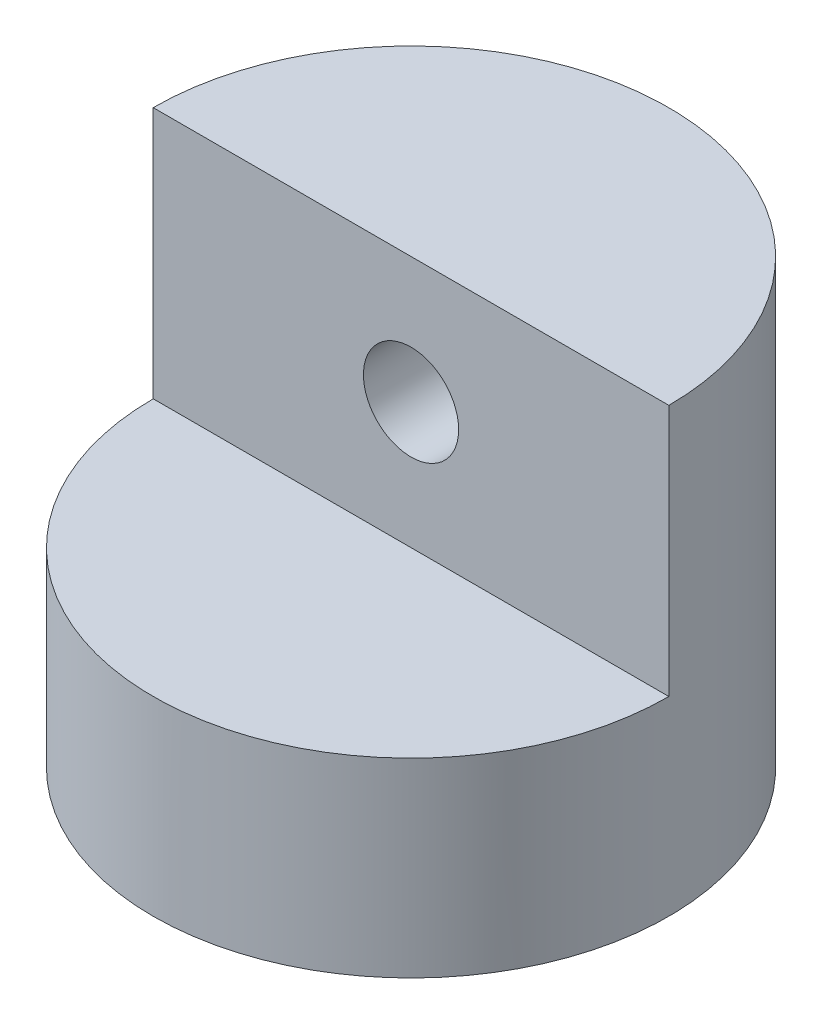
from build123d import *

# Parameters (mm, degrees)
SKETCH1_R           = 32.5
BOSS_EXTRUDE1_DEPTH = 55.788
CUT_EXTRUDE1_DEPTH  = 31.788
SKETCH3_R           = 8
SKETCH3_R_2         = 6
BOSS_EXTRUDE2_DEPTH = 2
SKETCH5_R           = 6
CUT_EXTRUDE3_DEPTH  = 46


with BuildPart() as part:
    # Sketch1 → Boss-Extrude1 (new body)
    with BuildSketch(Plane(origin=(0, 0, 0), x_dir=(1, 0, 0), z_dir=(0, 1, 0))):
        with Locations(Location((0, 0, 0), (0, 0, 270))):
            Circle(SKETCH1_R)
    extrude(amount=BOSS_EXTRUDE1_DEPTH)

    # Sketch2 → Cut-Extrude1 (cut)
    with BuildSketch(Plane(origin=(0, 55.788, 0), x_dir=(1, 0, 0), z_dir=(0, 1, 0))):
        with BuildLine():
            Line((32.5, 0), (-32.5, 0))
            ThreePointArc((-32.5, 0), (0, -32.5), (32.5, 0))
        make_face()
    extrude(amount=-CUT_EXTRUDE1_DEPTH, mode=Mode.SUBTRACT)

    # Sketch3 → Boss-Extrude2 (add)
    with BuildSketch(Plane(origin=(0, 0, 0), x_dir=(-1, 0, 0), z_dir=(0, -1, 0))):
        with Locations(Location((0, 0, 0), (0, 0, 270))):
            Circle(SKETCH3_R)
        with Locations(Location((0, 0, 0), (0, 0, 90))):
            Circle(SKETCH3_R_2, mode=Mode.SUBTRACT)
    extrude(amount=BOSS_EXTRUDE2_DEPTH)

    # Sketch5 → Cut-Extrude3 (cut)
    with BuildSketch(Plane.XY):
        with Locations((0, 39.894)):
            Circle(SKETCH5_R)
    extrude(amount=-CUT_EXTRUDE3_DEPTH, mode=Mode.SUBTRACT)


solid = part.part
